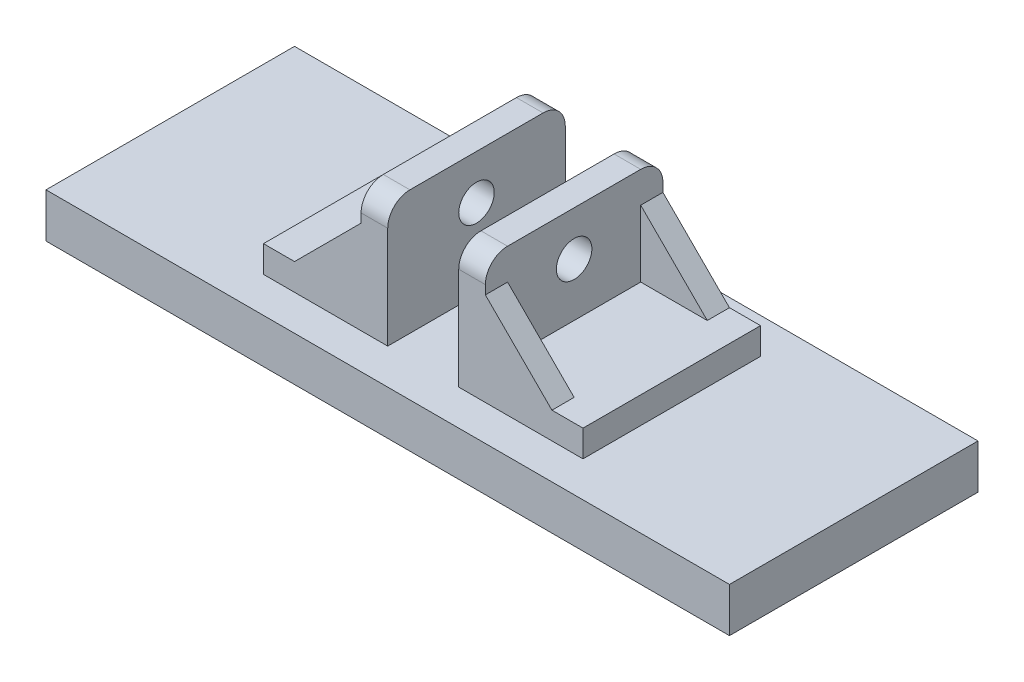
from build123d import *

# Parameters (mm, degrees)
SKETCH1_W           = 154
SKETCH1_H           = 56
PLATE_DEPTH         = 10
BOSS_EXTRUDE1_DEPTH = 20
CORNER_START        = -15
CORNER_DEPTH        = 5
CORNER2_START       = 15
CORNER2_DEPTH       = 5
SKETCH3_R           = 4
CUT_EXTRUDE1_DEPTH  = 28
FILLET1_R           = 5


with BuildPart() as part:
    # Sketch1 → plate (new body)
    with BuildSketch(Plane(origin=(0, 0, 0), x_dir=(1, 0, 0), z_dir=(0, 1, 0))):
        Rectangle(SKETCH1_W, SKETCH1_H)
    extrude(amount=PLATE_DEPTH)

    # Sketch2 → Boss-Extrude1 (add, symmetric)
    with BuildSketch(Plane.XY):
        Polygon((-8, 10), (-8, 38), (-14, 38), (-14, 16), (-36, 16), (-36, 10), align=None)
        Polygon((36, 16), (36, 10), (8, 10), (8, 38), (14, 38), (14, 16), align=None)
    extrude(amount=BOSS_EXTRUDE1_DEPTH, both=True)

    # Sketch2_4 → Corner (add)
    with BuildSketch(Plane.XY.offset(CORNER_START)):
        Polygon((-14, 16), (-14, 31), (-29, 16), align=None)
        Polygon((29, 16), (14, 31), (14, 16), align=None)
    extrude(amount=-CORNER_DEPTH)

    # Sketch2_3 → Corner2 (add)
    with BuildSketch(Plane.XY.offset(CORNER2_START)):
        Polygon((-14, 16), (-14, 31), (-29, 16), align=None)
        Polygon((29, 16), (14, 31), (14, 16), align=None)
    extrude(amount=CORNER2_DEPTH)

    # Sketch3 → Cut-Extrude1 (cut)
    with BuildSketch(Plane.ZY.offset(14)):
        with Locations((0, 28)):
            Circle(SKETCH3_R)
    extrude(amount=-CUT_EXTRUDE1_DEPTH, mode=Mode.SUBTRACT)

    # Fillet1
    fillet1_edges = [part.edges().sort_by_distance(p)[0] for p in [
        (-11, 38, -20),
        (-11, 38, 20),
        (11, 38, 20),
        (11, 38, -20),
    ]]
    fillet(fillet1_edges, radius=FILLET1_R)


solid = part.part
